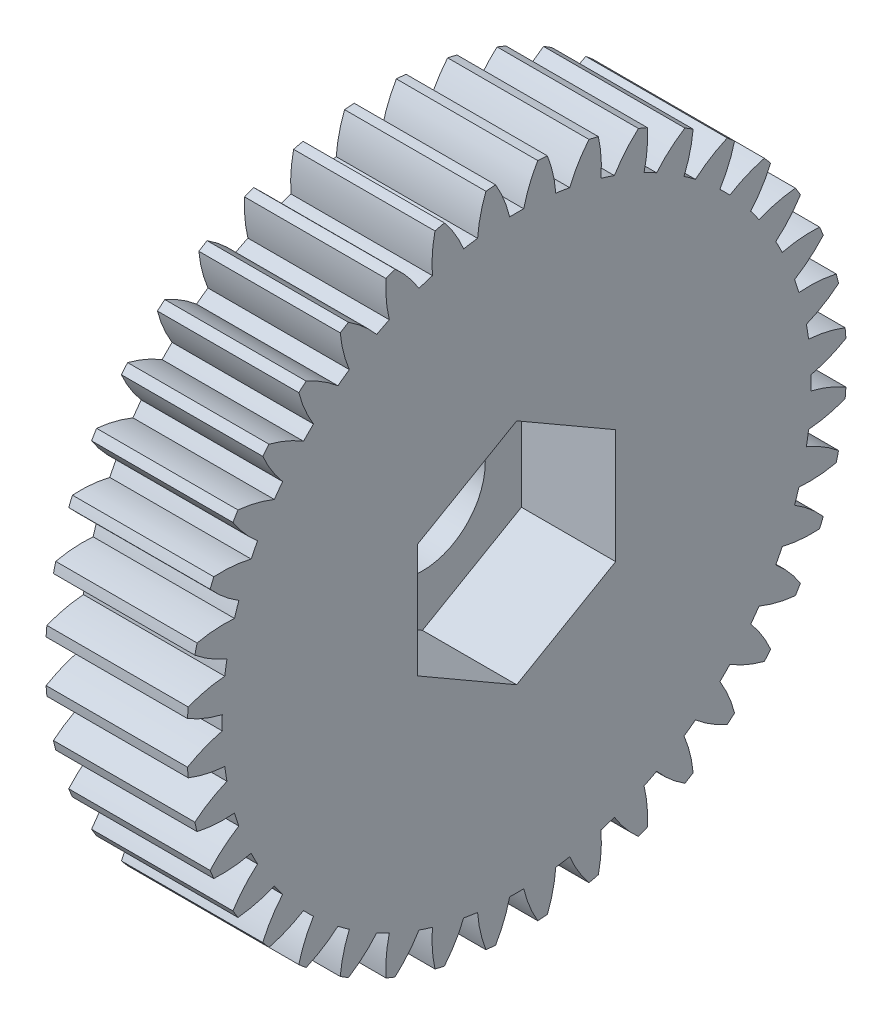
from build123d import *
from build123d.topology import SkipClean

# Parameters (mm, degrees)
BASPROSKE_W         = 9
BASPROSKE_H         = 21
TOOTHCUT_DEPTH      = 32.032241298
TEETHCUTS_COUNT     = 40
TEETHCUTS_ANGLE     = 351
BORSKE_R            = 2
BORE_DEPTH          = 50.0000508
CUT_EXTRUDE1_DEPTH  = 6
SKETCH1_7_R         = 4
CUT_EXTRUDE2_DEPTH  = 31.974304622
SKETCH2_R           = 6.5
SKETCH2_R_2         = 4
BOSS_EXTRUDE1_DEPTH = 1.8


with BuildPart() as part:
    # BasProSke → Base-Revolve (revolve)
    with BuildSketch(Plane(origin=(0, 0, 0), x_dir=(1, 0, 0), z_dir=(0, 1, 0))):
        with Locations((4.5, 10.5)):
            Rectangle(BASPROSKE_W, BASPROSKE_H)
    revolve(axis=Axis((-10, 0, 0), (1, 0, 0)))

    # TooCutSke → ToothCut (cut, through all)
    with BuildSketch(Plane(origin=(0, 0, 0), x_dir=(0, 0, -1), z_dir=(1, 0, 0))):
        with BuildLine():
            ThreePointArc((0.448673268, 18.74363074), (0, 18.749), (-0.448673268, 18.74363074))
            ThreePointArc((-0.448673268, 18.74363074), (-0.816786816, 19.89705013), (-1.354745081, 20.981708961))
            ThreePointArc((-1.354745081, 20.981708961), (0, 21.0254), (1.354745081, 20.981708961))
            ThreePointArc((1.354745081, 20.981708961), (0.816786816, 19.89705013), (0.448673268, 18.74363074))
        make_face()
    toothcut = extrude(amount=TOOTHCUT_DEPTH, mode=Mode.SUBTRACT)

    # TeethCuts: ToothCut ×40 about axis
    teethcuts_axis = Axis((-10, 0, 0), (1, 0, 0))
    for i in range(1, TEETHCUTS_COUNT):
        add(toothcut.rotate(teethcuts_axis, i * TEETHCUTS_ANGLE / (TEETHCUTS_COUNT - 1)), mode=Mode.SUBTRACT)

    # BorSke → Bore (cut, symmetric)
    with BuildSketch(Plane(origin=(0, 0, 0), x_dir=(0, 0, -1), z_dir=(1, 0, 0))):
        Circle(BORSKE_R)
    extrude(amount=BORE_DEPTH, both=True, mode=Mode.SUBTRACT)

    # Sketch1 → Cut-Extrude1 (cut)
    with BuildSketch(Plane(origin=(9, 0, 0), x_dir=(0, 0, -1), z_dir=(1, 0, 0))):
        Polygon((0, 7.274613392), (-6.3, 3.637306696), (-6.3, -3.637306696), (0, -7.274613392), (6.3, -3.637306696), (6.3, 3.637306696), align=None)
    extrude(amount=-CUT_EXTRUDE1_DEPTH, mode=Mode.SUBTRACT)

    # Sketch1_7 → Cut-Extrude2 (cut, through all)
    with BuildSketch(Plane(origin=(9, 0, 0), x_dir=(0, 0, -1), z_dir=(1, 0, 0))):
        Circle(SKETCH1_7_R)
    extrude(amount=-CUT_EXTRUDE2_DEPTH, mode=Mode.SUBTRACT)

    # Sketch2 → Boss-Extrude1 (add)
    with SkipClean():  # the faces are left unmerged after this step: merging them gives an invalid solid
        with BuildSketch(Plane.ZY):
            Circle(SKETCH2_R)
            Circle(SKETCH2_R_2, mode=Mode.SUBTRACT)
        extrude(amount=BOSS_EXTRUDE1_DEPTH)


solid = part.part
